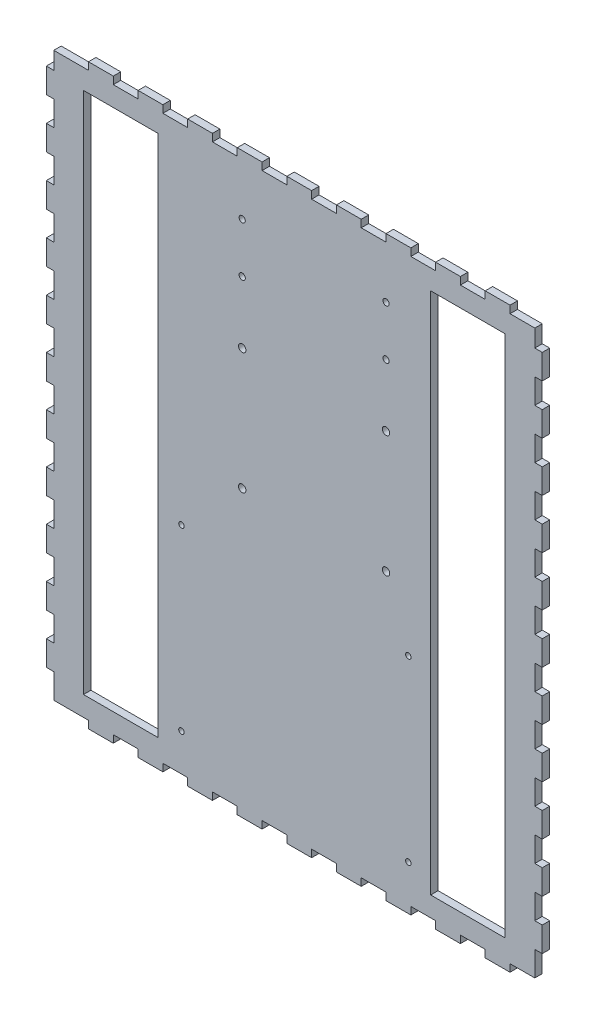
from build123d import *

# Parameters (mm, degrees)
SKETCH1_W           = 194
SKETCH1_H           = 227
BOSS_EXTRUDE1_DEPTH = 3
SKETCH2_W           = 3
SKETCH2_H           = 10
BOSS_EXTRUDE2_DEPTH = 3
LPATTERN1_COUNT     = 11
LPATTERN1_PITCH     = 20
SKETCH4_W           = 3
SKETCH4_H           = 10
BOSS_EXTRUDE3_DEPTH = 3
LPATTERN2_COUNT     = 11
LPATTERN2_PITCH     = 20
SKETCH5_W           = 10
SKETCH5_H           = 3
BOSS_EXTRUDE4_DEPTH = 3
LPATTERN3_COUNT     = 9
LPATTERN3_PITCH     = 20
SKETCH6_W           = 10
SKETCH6_H           = 3
BOSS_EXTRUDE5_DEPTH = 3
LPATTERN4_COUNT     = 9
LPATTERN4_PITCH     = 20
SKETCH7_W           = 30
SKETCH7_H           = 211
CUT_EXTRUDE1_DEPTH  = 4
SKETCH8_R           = 1.1
SKETCH8_R_2         = 1.5
SKETCH8_R_3         = 1.25
SKETCH8_W           = 30
SKETCH8_H           = 211
CUT_EXTRUDE2_DEPTH  = 4


with BuildPart() as part:
    # Sketch1 → Boss-Extrude1 (new body)
    with BuildSketch(Plane.XY):
        with Locations((97, 113.5)):
            Rectangle(SKETCH1_W, SKETCH1_H)
    extrude(amount=BOSS_EXTRUDE1_DEPTH)

    # Sketch2 → Boss-Extrude2 (add)
    with BuildSketch(Plane(origin=(194, 0, 0), x_dir=(0, 0, -1), z_dir=(1, 0, 0))):
        with Locations((-1.5, 15)):
            Rectangle(SKETCH2_W, SKETCH2_H)
    boss_extrude2 = extrude(amount=BOSS_EXTRUDE2_DEPTH)

    # LPattern1: Boss-Extrude2 ×11
    with Locations(*[(0, i * LPATTERN1_PITCH, 0) for i in range(1, LPATTERN1_COUNT)]):
        add(boss_extrude2)

    # Sketch4 → Boss-Extrude3 (add)
    with BuildSketch(Plane.ZY):
        with Locations((1.5, 15)):
            Rectangle(SKETCH4_W, SKETCH4_H)
    boss_extrude3 = extrude(amount=BOSS_EXTRUDE3_DEPTH)

    # LPattern2: Boss-Extrude3 ×11
    with Locations(*[(0, i * LPATTERN2_PITCH, 0) for i in range(1, LPATTERN2_COUNT)]):
        add(boss_extrude3)

    # Sketch5 → Boss-Extrude4 (add)
    with BuildSketch(Plane.XZ):
        with Locations((179, 1.5)):
            Rectangle(SKETCH5_W, SKETCH5_H)
    boss_extrude4 = extrude(amount=BOSS_EXTRUDE4_DEPTH)

    # LPattern3: Boss-Extrude4 ×9
    with Locations(*[(-i * LPATTERN3_PITCH, 0, 0) for i in range(1, LPATTERN3_COUNT)]):
        add(boss_extrude4)

    # Sketch6 → Boss-Extrude5 (add)
    with BuildSketch(Plane(origin=(0, 227, 0), x_dir=(1, 0, 0), z_dir=(0, 1, 0))):
        with Locations((179, -1.5)):
            Rectangle(SKETCH6_W, SKETCH6_H)
    boss_extrude5 = extrude(amount=BOSS_EXTRUDE5_DEPTH)

    # LPattern4: Boss-Extrude5 ×9
    with Locations(*[(-i * LPATTERN4_PITCH, 0, 0) for i in range(1, LPATTERN4_COUNT)]):
        add(boss_extrude5)

    # Sketch7 → Cut-Extrude1 (cut, through all)
    with BuildSketch(Plane.XY.offset(3)):
        with Locations((27, 113.5)):
            Rectangle(SKETCH7_W, SKETCH7_H)
    extrude(amount=-CUT_EXTRUDE1_DEPTH, mode=Mode.SUBTRACT)

    # Sketch8 → Cut-Extrude2 (cut, through all)
    with BuildSketch(Plane.XY.offset(3)):
        with Locations((143, 15)):
            Circle(SKETCH8_R)
        with Locations((51.5, 15)):
            Circle(SKETCH8_R)
        with Locations((143, 87)):
            Circle(SKETCH8_R)
        with Locations((51.5, 87)):
            Circle(SKETCH8_R)
        with Locations((134, 112)):
            Circle(SKETCH8_R_2)
        with Locations((76, 112)):
            Circle(SKETCH8_R_2)
        with Locations((134, 161)):
            Circle(SKETCH8_R_2)
        with Locations((76, 161)):
            Circle(SKETCH8_R_2)
        with Locations((76, 186)):
            Circle(SKETCH8_R_3)
        with Locations((76, 206)):
            Circle(SKETCH8_R_3)
        with Locations((134, 186)):
            Circle(SKETCH8_R_3)
        with Locations((134, 206)):
            Circle(SKETCH8_R_3)
        with Locations((167, 113.5)):
            Rectangle(SKETCH8_W, SKETCH8_H)
    extrude(amount=-CUT_EXTRUDE2_DEPTH, mode=Mode.SUBTRACT)


solid = part.part
